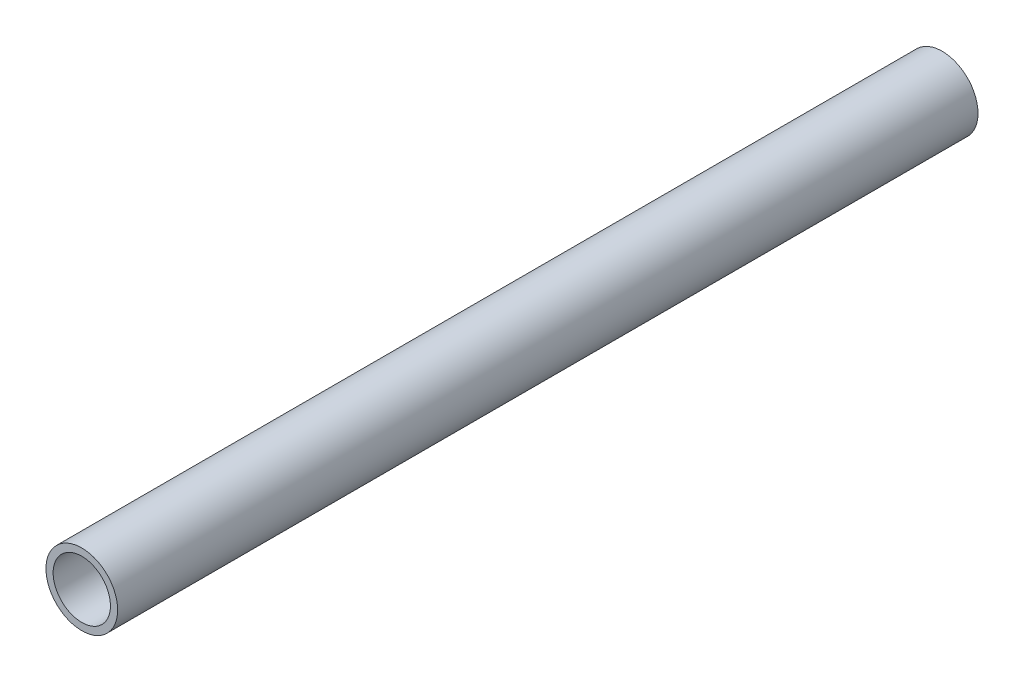
from build123d import *

# Parameters (mm, degrees)
SKETCH1_R           = 1.25
BOSS_EXTRUDE1_DEPTH = 30
SKETCH4_R           = 1
CUT_EXTRUDE1_DEPTH  = 30


with BuildPart() as part:
    # Sketch1 → Boss-Extrude1 (new body)
    with BuildSketch(Plane.XY):
        Circle(SKETCH1_R)
    extrude(amount=BOSS_EXTRUDE1_DEPTH)

    # Sketch4 → Cut-Extrude1 (cut)
    with BuildSketch(Plane(origin=(0, 0, 0), x_dir=(-1, 0, 0), z_dir=(0, 0, -1))):
        Circle(SKETCH4_R)
    extrude(amount=-CUT_EXTRUDE1_DEPTH, mode=Mode.SUBTRACT)


solid = part.part
